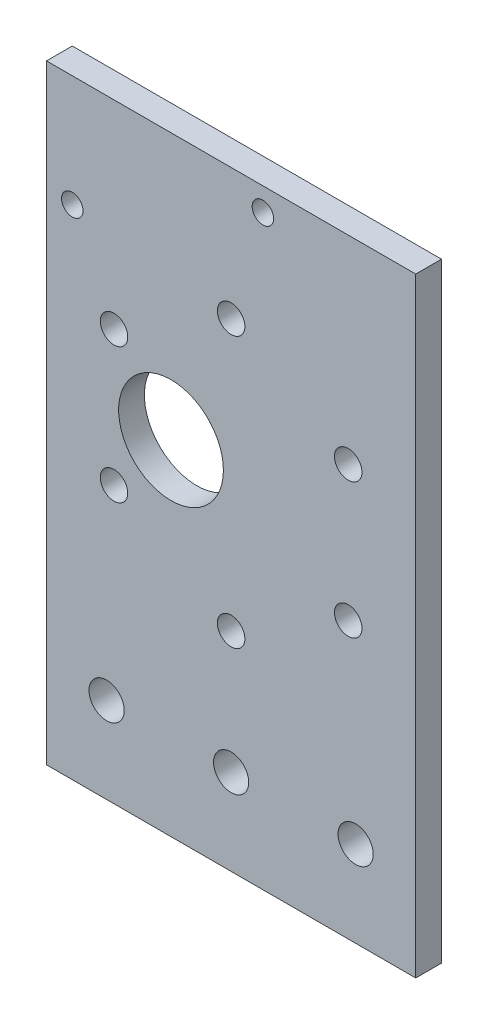
from build123d import *

# Parameters (mm, degrees)
SKETCH_1_W               = 40
SKETCH_1_H               = 29
EXTRUDE_1_DEPTH          = 3
CUT_EXTRUDE_1_DEPTH      = 3
SKETCH_3_W               = 40
SKETCH_3_H               = 3
EXTRUDE_2_DEPTH          = 10
SKETCH_4_W               = 40
SKETCH_4_H               = 3
EXTRUDE_3_DEPTH          = 10
SKETCH_6_W               = 3
SKETCH_6_H               = 49
EXTRUDE_5_DEPTH          = 42
SKETCH_8_W               = 3
SKETCH_8_H               = 49
EXTRUDE_6_DEPTH          = 2
SKETCH_9_W               = 3
SKETCH_9_H               = 49
EXTRUDE_7_DEPTH          = 2
SKETCH_10_W              = 86
SKETCH_10_H              = 3
EXTRUDE_8_DEPTH          = 10
SKETCH_11_W              = 86
SKETCH_11_H              = 3
EXTRUDE_9_DEPTH          = 10
SKETCH_14_W              = 3
SKETCH_14_H              = 69
CUT_EXTRUDE_5_DEPTH      = 43
SKETCH_17_W              = 43
SKETCH_17_H              = 3
EXTRUDE_10_DEPTH         = 20
SKETCH_18_R              = 2.05
CUT_EXTRUDE_6_DEPTH      = 10
SKETCH_20_W              = 43
SKETCH_20_H              = 3
EXTRUDE_11_DEPTH         = 10
SKETCH_21_W              = 43
SKETCH_21_H              = 3
CUT_EXTRUDE_7_DEPTH      = 10
SKETCH_24_W              = 43
SKETCH_24_H              = 3
EXTRUDE_12_DEPTH         = 10
SKETCH_28_R              = 1.6
SKETCH_28_R_2            = 6.1
CUT_EXTRUDE_9_DEPTH      = 10
SKETCH_29_W              = 43
SKETCH_29_H              = 3
CUT_EXTRUDE_10_DEPTH     = 20
SKETCH_30_R              = 2.05
CUT_EXTRUDE_11_DEPTH     = 10
M3X0_5_1_D               = 2.5
M3X0_5_1_DEPTH           = 8.5
M3X0_5_1_TIP             = 0.751075774
M3X0_5_1_ON_FACE_2_D     = 2.5
M3X0_5_1_ON_FACE_2_DEPTH = 8.5
M3X0_5_1_ON_FACE_2_TIP   = 0.751075774
SKETCH_32_W              = 43
SKETCH_32_H              = 3
CUT_EXTRUDE_12_DEPTH     = 8


with BuildPart() as part:
    # ｽｹｯﾁ1 → ﾎﾞｽ - 押し出し1 (new body)
    with BuildSketch(Plane.XY):
        Rectangle(SKETCH_1_W, SKETCH_1_H)
    extrude(amount=EXTRUDE_1_DEPTH)

    # ｽｹｯﾁ2 → ｶｯﾄ - 押し出し1 (cut)
    with BuildSketch(Plane.XY.offset(3)):
        with BuildLine():
            ThreePointArc((-14.4, 10.5), (-15.01507576, 11.98492424), (-16.5, 12.6))
            Line((-16.5, 12.6), (-16.5, 10.5))
            Line((-16.5, 10.5), (-18.6, 10.5))
            ThreePointArc((-18.6, 10.5), (-16.5, 8.4), (-14.4, 10.5))
        make_face()
        with BuildLine():
            Line((-16.5, 10.5), (-16.5, 12.6))
            ThreePointArc((-16.5, 12.6), (-17.98492424, 11.98492424), (-18.6, 10.5))
            Line((-18.6, 10.5), (-16.5, 10.5))
        make_face()
        with BuildLine():
            ThreePointArc((-18.6, -10.5), (-17.98492424, -11.98492424), (-16.5, -12.6))
            Line((-16.5, -12.6), (-16.5, -10.5))
            Line((-16.5, -10.5), (-18.6, -10.5))
        make_face()
        with BuildLine():
            Line((-16.5, -10.5), (-16.5, -12.6))
            ThreePointArc((-16.5, -12.6), (-15.01507576, -11.98492424), (-14.4, -10.5))
            ThreePointArc((-14.4, -10.5), (-16.5, -8.4), (-18.6, -10.5))
            Line((-18.6, -10.5), (-16.5, -10.5))
        make_face()
        with BuildLine():
            ThreePointArc((18.6, -10.5), (15.01507576, -9.01507576), (16.5, -12.6))
            Line((16.5, -12.6), (16.5, -10.5))
            Line((16.5, -10.5), (18.6, -10.5))
        make_face()
        with BuildLine():
            Line((16.5, -10.5), (16.5, -12.6))
            ThreePointArc((16.5, -12.6), (17.98492424, -11.98492424), (18.6, -10.5))
            Line((18.6, -10.5), (16.5, -10.5))
        make_face()
        with BuildLine():
            ThreePointArc((18.6, 10.5), (17.98492424, 11.98492424), (16.5, 12.6))
            Line((16.5, 12.6), (16.5, 10.5))
            Line((16.5, 10.5), (18.6, 10.5))
        make_face()
        with BuildLine():
            Line((16.5, 10.5), (16.5, 12.6))
            ThreePointArc((16.5, 12.6), (15.01507576, 9.01507576), (18.6, 10.5))
            Line((18.6, 10.5), (16.5, 10.5))
        make_face()
    extrude(amount=-CUT_EXTRUDE_1_DEPTH, mode=Mode.SUBTRACT)

    # ｽｹｯﾁ3 → ﾎﾞｽ - 押し出し2 (add)
    with BuildSketch(Plane.XZ.offset(14.5)):
        with Locations((0, 1.5)):
            Rectangle(SKETCH_3_W, SKETCH_3_H)
    extrude(amount=EXTRUDE_2_DEPTH)

    # ｽｹｯﾁ4 → ﾎﾞｽ - 押し出し3 (add)
    with BuildSketch(Plane(origin=(0, 14.5, 0), x_dir=(1, 0, 0), z_dir=(0, 1, 0))):
        with Locations((0, -1.5)):
            Rectangle(SKETCH_4_W, SKETCH_4_H)
    extrude(amount=EXTRUDE_3_DEPTH)

    # ｽｹｯﾁ6 → ﾎﾞｽ - 押し出し5 (add)
    with BuildSketch(Plane(origin=(20, 0, 0), x_dir=(0, 0, -1), z_dir=(1, 0, 0))):
        with Locations((-1.5, 0)):
            Rectangle(SKETCH_6_W, SKETCH_6_H)
    extrude(amount=EXTRUDE_5_DEPTH)

    # ｽｹｯﾁ8 → ﾎﾞｽ - 押し出し6 (add)
    with BuildSketch(Plane.ZY.offset(20)):
        with Locations((1.5, 0)):
            Rectangle(SKETCH_8_W, SKETCH_8_H)
    extrude(amount=EXTRUDE_6_DEPTH)

    # ｽｹｯﾁ9 → ﾎﾞｽ - 押し出し7 (add)
    with BuildSketch(Plane(origin=(62, 0, 0), x_dir=(0, 0, -1), z_dir=(1, 0, 0))):
        with Locations((-1.5, 0)):
            Rectangle(SKETCH_9_W, SKETCH_9_H)
    extrude(amount=EXTRUDE_7_DEPTH)

    # ｽｹｯﾁ10 → ﾎﾞｽ - 押し出し8 (add)
    with BuildSketch(Plane.XZ.offset(24.5)):
        with Locations((21, 1.5)):
            Rectangle(SKETCH_10_W, SKETCH_10_H)
    extrude(amount=EXTRUDE_8_DEPTH)

    # ｽｹｯﾁ11 → ﾎﾞｽ - 押し出し9 (add)
    with BuildSketch(Plane(origin=(0, 24.5, 0), x_dir=(1, 0, 0), z_dir=(0, 1, 0))):
        with Locations((21, -1.5)):
            Rectangle(SKETCH_11_W, SKETCH_11_H)
    extrude(amount=EXTRUDE_9_DEPTH)

    # ｽｹｯﾁ14 → ｶｯﾄ - 押し出し5 (cut)
    with BuildSketch(Plane.ZY.offset(22)):
        with Locations((1.5, 0)):
            Rectangle(SKETCH_14_W, SKETCH_14_H)
    extrude(amount=-CUT_EXTRUDE_5_DEPTH, mode=Mode.SUBTRACT)

    # ｽｹｯﾁ17 → ﾎﾞｽ - 押し出し10 (add)
    with BuildSketch(Plane.XZ.offset(34.5)):
        with Locations((42.5, 1.5)):
            Rectangle(SKETCH_17_W, SKETCH_17_H)
    extrude(amount=EXTRUDE_10_DEPTH)

    # ｽｹｯﾁ18 → ｶｯﾄ - 押し出し6 (cut)
    with BuildSketch(Plane.XY.offset(3)):
        with Locations((28, -34.5)):
            Circle(SKETCH_18_R)
        with Locations((57, -34.5)):
            Circle(SKETCH_18_R)
    extrude(amount=-CUT_EXTRUDE_6_DEPTH, mode=Mode.SUBTRACT)

    # ｽｹｯﾁ20 → ﾎﾞｽ - 押し出し11 (add)
    with BuildSketch(Plane.XZ.offset(54.5)):
        with Locations((42.5, 1.5)):
            Rectangle(SKETCH_20_W, SKETCH_20_H)
    extrude(amount=EXTRUDE_11_DEPTH)

    # ｽｹｯﾁ21 → ｶｯﾄ - 押し出し7 (cut)
    with BuildSketch(Plane(origin=(0, 34.5, 0), x_dir=(1, 0, 0), z_dir=(0, 1, 0))):
        with Locations((42.5, -1.5)):
            Rectangle(SKETCH_21_W, SKETCH_21_H)
    extrude(amount=-CUT_EXTRUDE_7_DEPTH, mode=Mode.SUBTRACT)

    # ｽｹｯﾁ24 → ﾎﾞｽ - 押し出し12 (add)
    with BuildSketch(Plane(origin=(0, 24.5, 0), x_dir=(1, 0, 0), z_dir=(0, 1, 0))):
        with Locations((42.5, -1.5)):
            Rectangle(SKETCH_24_W, SKETCH_24_H)
    extrude(amount=EXTRUDE_12_DEPTH)

    # ｽｹｯﾁ28 → ｶｯﾄ - 押し出し9 (cut)
    with BuildSketch(Plane.XY.offset(3)):
        with Locations((42.5, 11.25)):
            Circle(SKETCH_28_R)
        with Locations((28.86009989, 3.375)):
            Circle(SKETCH_28_R)
        with Locations((56.13990011, 3.375)):
            Circle(SKETCH_28_R)
        with Locations((35.5, -4.5)):
            Circle(SKETCH_28_R_2)
        with Locations((56.13990011, -12.375)):
            Circle(SKETCH_28_R)
        with Locations((42.5, -20.25)):
            Circle(SKETCH_28_R)
        with Locations((28.86009989, -12.375)):
            Circle(SKETCH_28_R)
    extrude(amount=-CUT_EXTRUDE_9_DEPTH, mode=Mode.SUBTRACT)

    # ｽｹｯﾁ29 → ｶｯﾄ - 押し出し10 (cut)
    with BuildSketch(Plane(origin=(0, -64.5, 0), x_dir=(-1, 0, 0), z_dir=(0, -1, 0))):
        with Locations((-42.5, -1.5)):
            Rectangle(SKETCH_29_W, SKETCH_29_H)
    extrude(amount=-CUT_EXTRUDE_10_DEPTH, mode=Mode.SUBTRACT)

    # ｽｹｯﾁ30 → ｶｯﾄ - 押し出し11 (cut)
    with BuildSketch(Plane.XY.offset(3)):
        with Locations((42.5, -34.5)):
            Circle(SKETCH_30_R)
    extrude(amount=-CUT_EXTRUDE_11_DEPTH, mode=Mode.SUBTRACT)

    # M3x0.5 ねじ穴1
    with Locations(Plane(origin=(24, 13.5, 3), x_dir=(1, 0, 0), z_dir=(0, 0, 1))):
        with Locations((0, 0), (22.2, 10.3)):
            Hole(M3X0_5_1_D / 2, depth=M3X0_5_1_DEPTH)
            with Locations((0, 0, -(M3X0_5_1_DEPTH + M3X0_5_1_TIP / 2))):  # 118° drill point
                Cone(0, M3X0_5_1_D / 2, M3X0_5_1_TIP, mode=Mode.SUBTRACT)

    # M3x0.5 ねじ穴1 on face 2
    with Locations(Plane(origin=(29.171215171, -61.022508803, 0), x_dir=(1, 0, 0), z_dir=(0, 0, 1))):
        with Locations((0, 0)):
            Hole(M3X0_5_1_ON_FACE_2_D / 2, depth=M3X0_5_1_ON_FACE_2_DEPTH)
            with Locations((0, 0, -(M3X0_5_1_ON_FACE_2_DEPTH + M3X0_5_1_ON_FACE_2_TIP / 2))):  # 118° drill point
                Cone(0, M3X0_5_1_ON_FACE_2_D / 2, M3X0_5_1_ON_FACE_2_TIP, mode=Mode.SUBTRACT)

    # ｽｹｯﾁ32 → ｶｯﾄ - 押し出し12 (cut)
    with BuildSketch(Plane(origin=(0, 34.5, 0), x_dir=(1, 0, 0), z_dir=(0, 1, 0))):
        with Locations((42.5, -1.5)):
            Rectangle(SKETCH_32_W, SKETCH_32_H)
    extrude(amount=-CUT_EXTRUDE_12_DEPTH, mode=Mode.SUBTRACT)


solid = part.part
